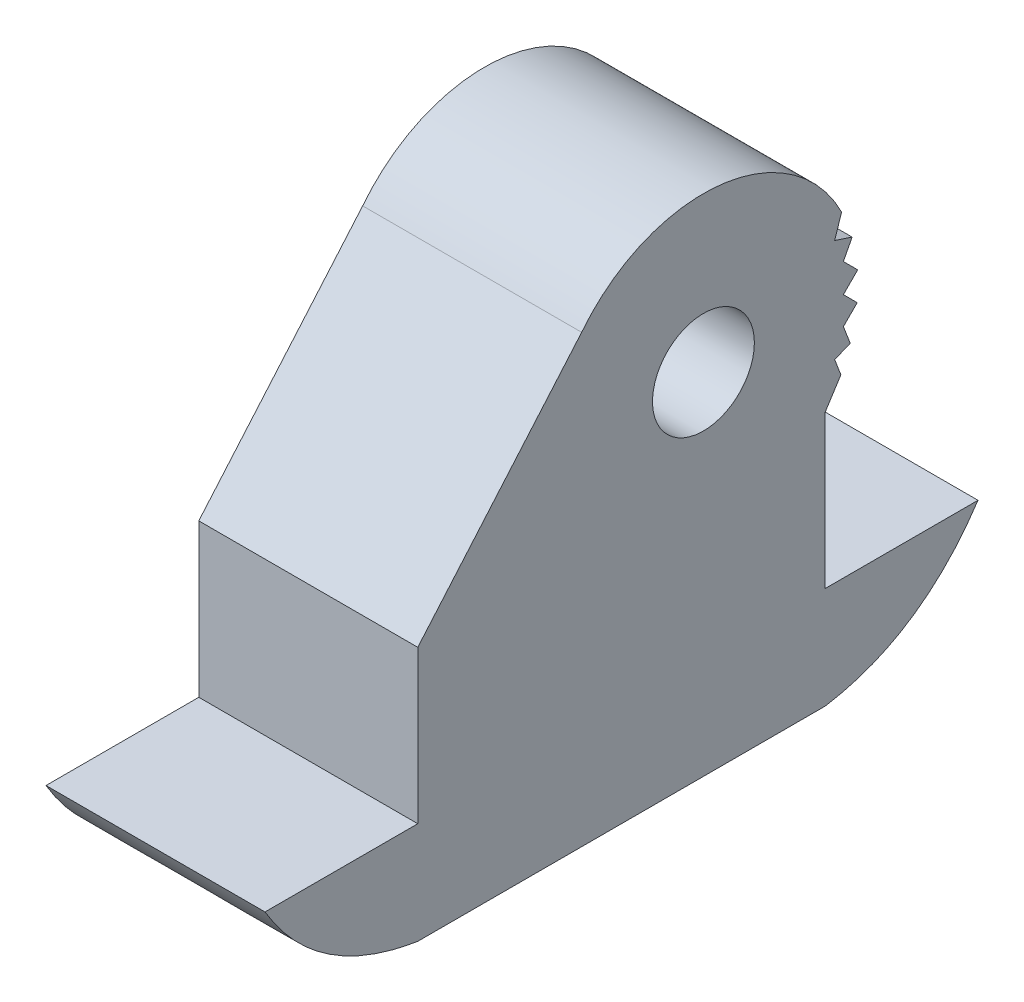
from build123d import *

# Parameters (mm, degrees)
SKETCH_1_W      = 4.3
SKETCH_1_H      = 8
EXTRUDE_1_DEPTH = 5
EXTRUDE_2_DEPTH = 4.3
SKETCH_3_R      = 1
EXTRUDE_3_DEPTH = 4.3


with BuildPart() as part:
    # 草图1 → 凸台-拉伸1 (new body)
    with BuildSketch(Plane(origin=(0, 0, 0), x_dir=(1, 0, 0), z_dir=(0, 1, 0))):
        Rectangle(SKETCH_1_W, SKETCH_1_H)
    extrude(amount=EXTRUDE_1_DEPTH)

    # 草图2 → 凸台-拉伸2 (add)
    with BuildSketch(Plane(origin=(2.15, 0, 0), x_dir=(0, 0, -1), z_dir=(1, 0, 0))):
        with BuildLine():
            Line((-4, 2), (-7, 2))
            add(Edge.make_bspline(
                [(-7, 2), (-6.002659385, 0.317190086), (-4, 0)],
                knots=[0, 0, 0, 1, 1, 1], degree=2))
            Line((-4, 0), (-4, 2))
        make_face()
        with BuildLine():
            Line((4, 2), (7, 2))
            add(Edge.make_bspline(
                [(4, 0), (5.86881421, 0.295991093), (7, 2)],
                knots=[0, 0, 0, 1, 1, 1], degree=2))
            Line((4, 0), (4, 2))
        make_face()
    extrude(amount=-EXTRUDE_2_DEPTH)

    # 草图3 → 凸台-拉伸3 (add)
    with BuildSketch(Plane(origin=(2.15, 0, 0), x_dir=(0, 0, -1), z_dir=(1, 0, 0))):
        with BuildLine():
            Line((-4, 5), (-0.782236668, 8.747328908))
            ThreePointArc((-0.782236668, 8.747328908), (1.909340646, 9.896542185), (4.322038795, 8.239989368))
            Line((4.322038795, 8.239989368), (4.184905625, 7.825161592))
            Line((4.184905625, 7.825161592), (4.528840035, 7.711464249))
            Line((4.528840035, 7.711464249), (4.35687283, 7.38145986))
            Line((4.35687283, 7.38145986), (4.638246106, 7.099532702))
            Line((4.638246106, 7.099532702), (4.35687283, 6.81871222))
            Line((4.35687283, 6.81871222), (4.628943103, 6.546106378))
            Line((4.628943103, 6.546106378), (4.35687283, 6.274570623))
            Line((4.35687283, 6.274570623), (4.492907966, 5.919485397))
            Line((4.492907966, 5.919485397), (4.184905625, 5.801487977))
            Line((4.184905625, 5.801487977), (4.3080813, 5.479969112))
            Line((4.3080813, 5.479969112), (4, 5))
            Line((4, 5), (-4, 5))
        make_face()
        with Locations((1.608881666, 6.873664454)):
            Circle(SKETCH_3_R, mode=Mode.SUBTRACT)
    extrude(amount=-EXTRUDE_3_DEPTH)


solid = part.part
